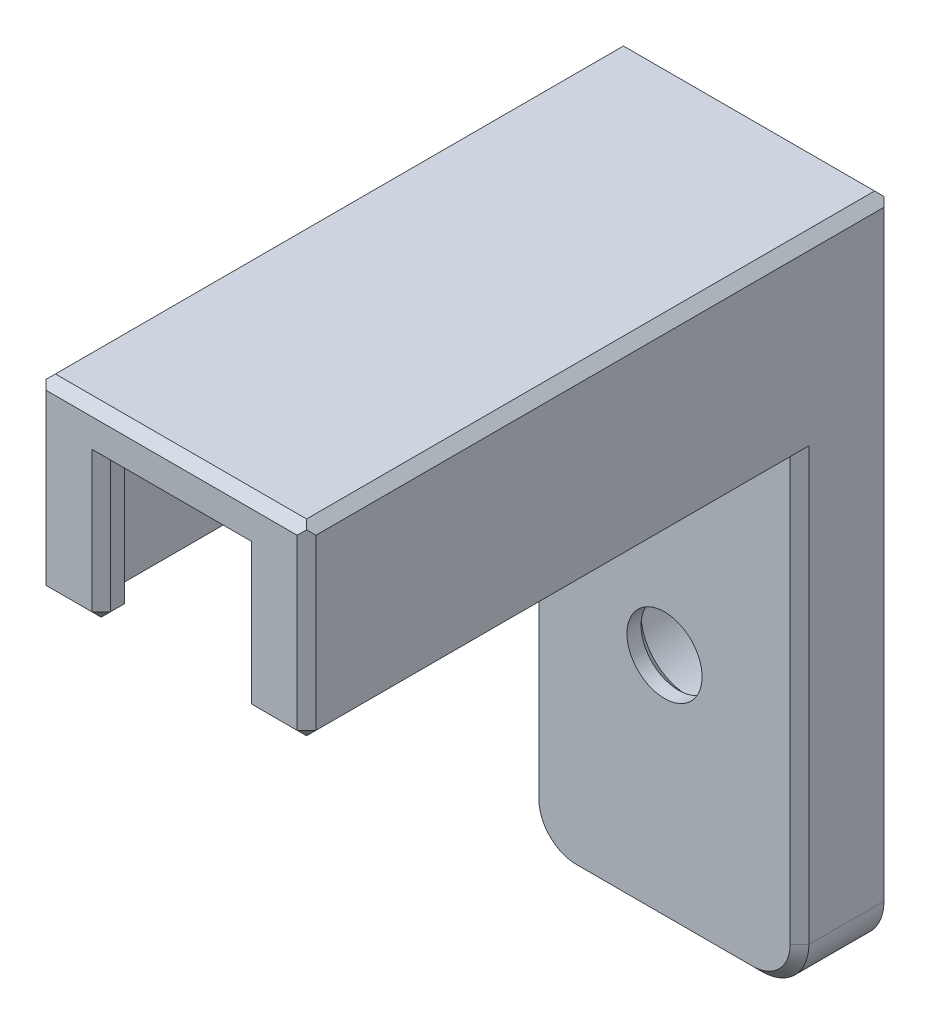
from build123d import *

# Parameters (mm, degrees)
SKETCH1_W                      = 11.5
SKETCH1_H                      = 25
BOSS_EXTRUDE1_DEPTH            = 8
CUT_EXTRUDE1_DEPTH             = 6
SKETCH3_W                      = 11.5
SKETCH3_H                      = 4
BOSS_EXTRUDE2_DEPTH            = 20
CBORE_FOR_M3_SHCS1_D           = 3.2
CBORE_FOR_M3_SHCS1_CBORE_D     = 6.6
CBORE_FOR_M3_SHCS1_CBORE_DEPTH = 3
FILLET1_R                      = 2
CHAMFER1_SIZE                  = 0.4
CHAMFER2_SIZE                  = 0.4


with BuildPart() as part:
    # Sketch1 → Boss-Extrude1 (new body)
    with BuildSketch(Plane(origin=(0, 0, 0), x_dir=(1, 0, 0), z_dir=(0, 1, 0))):
        Rectangle(SKETCH1_W, SKETCH1_H)
    extrude(amount=BOSS_EXTRUDE1_DEPTH)

    # Sketch2 → Cut-Extrude1 (cut)
    with BuildSketch(Plane.XZ):
        Polygon((-3, 12.5), (3, 12.5), (3, 11.5), (3.8, 11.5), (3.8, 4.5), (3, 4.5), (3, -2.5), (-3, -2.5), (-3, 4.5), (-3.8, 4.5), (-3.8, 11.5), (-3, 11.5), align=None)
    extrude(amount=-CUT_EXTRUDE1_DEPTH, mode=Mode.SUBTRACT)

    # Sketch3 → Boss-Extrude2 (add)
    with BuildSketch(Plane.XZ):
        with Locations((0, -10.5)):
            Rectangle(SKETCH3_W, SKETCH3_H)
    extrude(amount=BOSS_EXTRUDE2_DEPTH)

    # CBORE for M3 SHCS1 (through all)
    with Locations(Plane(origin=(0, 0, -12.5), x_dir=(-1, 0, 0), z_dir=(0, 0, -1))):
        with Locations((0, -10)):
            CounterBoreHole(CBORE_FOR_M3_SHCS1_D / 2, CBORE_FOR_M3_SHCS1_CBORE_D / 2, CBORE_FOR_M3_SHCS1_CBORE_DEPTH)

    # Fillet1
    fillet1_edges = [part.edges().sort_by_distance(p)[0] for p in [
        (-5.75, -20, -10.5),
        (5.75, -20, -10.5),
    ]]
    fillet(fillet1_edges, radius=FILLET1_R)

    # Chamfer1
    chamfer1_edges = [part.edges().sort_by_distance(p)[0] for p in [
        (5.75, 8, 0),
        (0, 8, -12.5),
        (-5.75, 8, 0),
        (0, 8, 12.5),
    ]]
    chamfer(chamfer1_edges, length=CHAMFER1_SIZE)

    # Chamfer2
    chamfer2_edges = [part.edges().sort_by_distance(p)[0] for p in [
        (4.375, 0, 12.5),
        (-3, 0, 12),
        (-3.4, 0, 11.5),
        (-3.8, 0, 8),
        (-3.4, 0, 4.5),
        (-3, 0, 1),
        (0, 0, -2.5),
        (3, 0, 1),
        (3.4, 0, 4.5),
        (3.8, 0, 8),
        (3.4, 0, 11.5),
        (3, 0, 12),
        (3, 3, 12.5),
        (0, 6, 12.5),
        (-3, 3, 12.5),
        (-5.75, 0, 2),
        (5.75, 0, 2),
        (-4.375, 0, 12.5),
        (3.3, -10, -12.5),
        (-1.6, -10, -9.5),
        (0, -20, -12.5),
        (0, -20, -8.5),
        (5.164213562, -19.414213562, -12.5),
        (-5.164213562, -19.414213562, -12.5),
        (-5.75, -9, -8.5),
        (5.75, -9, -8.5),
        (5.164213562, -19.414213562, -8.5),
        (-5.164213562, -19.414213562, -8.5),
        (-5.75, -5.2, -12.5),
        (5.75, -5.2, -12.5),
        (5.75, 3.8, 12.5),
        (-5.75, 3.8, 12.5),
    ]]
    chamfer(chamfer2_edges, length=CHAMFER2_SIZE)


solid = part.part
